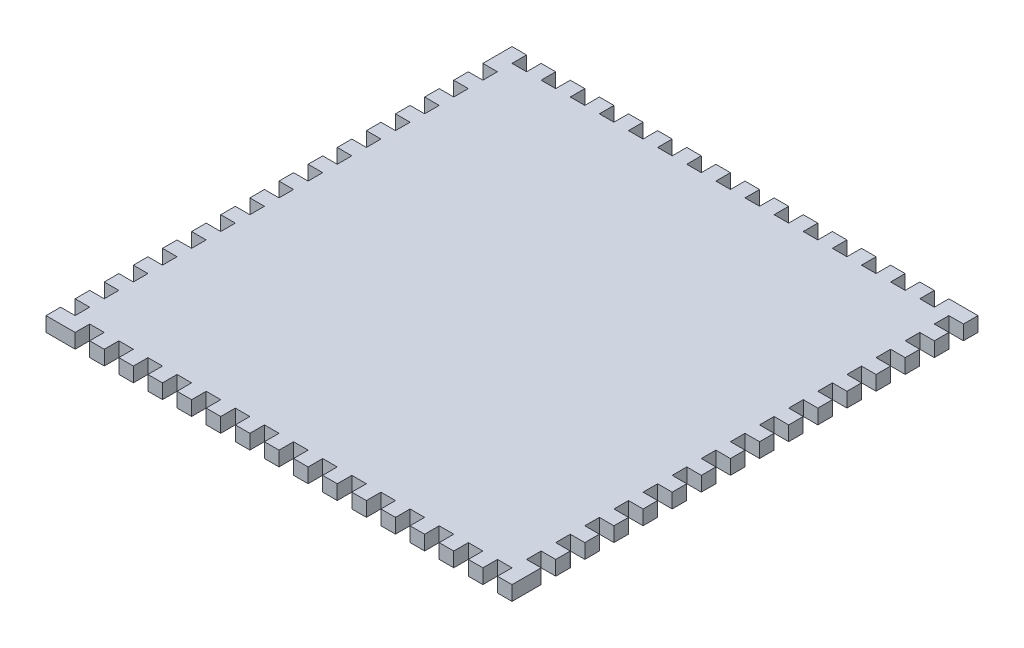
from build123d import *

# Parameters (mm, degrees)
SKETCH1_W           = 203.2
SKETCH1_H           = 203.2
BOSS_EXTRUDE1_DEPTH = 6.35
SKETCH3_W           = 6.35
SKETCH3_H           = 6.35
CUT_EXTRUDE1_DEPTH  = 6.35
LPATTERN3_COUNT     = 16
LPATTERN3_PITCH     = 12.7
SKETCH5_W           = 6.35
SKETCH5_H           = 6.35
CUT_EXTRUDE3_DEPTH  = 6.35
LPATTERN4_COUNT     = 15
LPATTERN4_PITCH     = 12.7
SKETCH6_W           = 6.35
SKETCH6_H           = 6.35
CUT_EXTRUDE4_DEPTH  = 6.35
LPATTERN5_COUNT     = 15
LPATTERN5_PITCH     = 12.7
SKETCH7_W           = 6.35
SKETCH7_H           = 6.35
CUT_EXTRUDE5_DEPTH  = 6.35
LPATTERN6_COUNT     = 15
LPATTERN6_PITCH     = 12.7
SKETCH9_W           = 6.35
SKETCH9_H           = 6.35
BOSS_EXTRUDE2_DEPTH = 6.35


with BuildPart() as part:
    # Sketch1 → Boss-Extrude1 (new body)
    with BuildSketch(Plane(origin=(0, 0, 0), x_dir=(1, 0, 0), z_dir=(0, 1, 0))):
        with Locations((101.6, 101.6)):
            Rectangle(SKETCH1_W, SKETCH1_H)
    extrude(amount=BOSS_EXTRUDE1_DEPTH)

    # Sketch3 → Cut-Extrude1 (cut)
    with BuildSketch(Plane.XY):
        with Locations((200.025, 3.175)):
            Rectangle(SKETCH3_W, SKETCH3_H)
    cut_extrude1 = extrude(amount=-CUT_EXTRUDE1_DEPTH, mode=Mode.SUBTRACT)

    # LPattern3: Cut-Extrude1 ×16
    with Locations(*[(0, 0, -i * LPATTERN3_PITCH) for i in range(1, LPATTERN3_COUNT)]):
        add(cut_extrude1, mode=Mode.SUBTRACT)

    # Sketch5 → Cut-Extrude3 (cut)
    with BuildSketch(Plane(origin=(0, 0, -203.2), x_dir=(-1, 0, 0), z_dir=(0, 0, -1))):
        with Locations((-187.325, 3.175)):
            Rectangle(SKETCH5_W, SKETCH5_H)
    cut_extrude3 = extrude(amount=-CUT_EXTRUDE3_DEPTH, mode=Mode.SUBTRACT)

    # LPattern4: Cut-Extrude3 ×15
    with Locations(*[(-i * LPATTERN4_PITCH, 0, 0) for i in range(1, LPATTERN4_COUNT)]):
        add(cut_extrude3, mode=Mode.SUBTRACT)

    # Sketch6 → Cut-Extrude4 (cut)
    with BuildSketch(Plane.ZY):
        with Locations((-187.325, 3.175)):
            Rectangle(SKETCH6_W, SKETCH6_H)
    cut_extrude4 = extrude(amount=-CUT_EXTRUDE4_DEPTH, mode=Mode.SUBTRACT)

    # LPattern5: Cut-Extrude4 ×15
    with Locations(*[(0, 0, i * LPATTERN5_PITCH) for i in range(1, LPATTERN5_COUNT)]):
        add(cut_extrude4, mode=Mode.SUBTRACT)

    # Sketch7 → Cut-Extrude5 (cut)
    with BuildSketch(Plane.XY):
        with Locations((15.875, 3.175)):
            Rectangle(SKETCH7_W, SKETCH7_H)
    cut_extrude5 = extrude(amount=-CUT_EXTRUDE5_DEPTH, mode=Mode.SUBTRACT)

    # LPattern6: Cut-Extrude5 ×15
    with Locations(*[(i * LPATTERN6_PITCH, 0, 0) for i in range(1, LPATTERN6_COUNT)]):
        add(cut_extrude5, mode=Mode.SUBTRACT)

    # Sketch9 → Boss-Extrude2 (add)
    with BuildSketch(Plane.XY.offset(-6.35)):
        with Locations((200.025, 3.175)):
            Rectangle(SKETCH9_W, SKETCH9_H)
    extrude(amount=BOSS_EXTRUDE2_DEPTH)


solid = part.part
